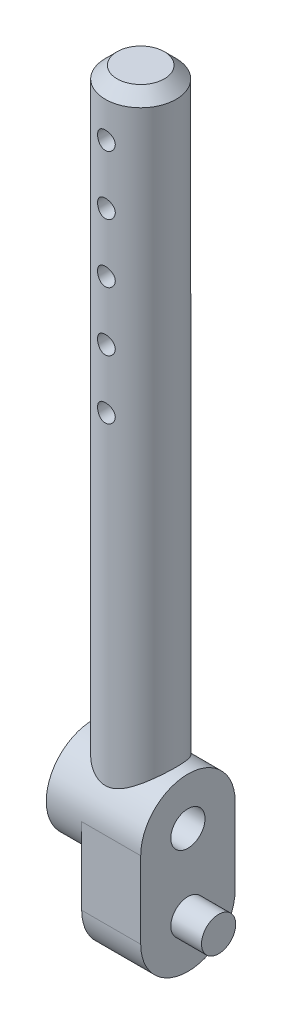
from build123d import *

# Parameters (mm, degrees)
SKETCH1_R               = 1.45
BOSS_EXTRUDE1_DEPTH     = 5
SKETCH2_R               = 1.45
BOSS_EXTRUDE2_DEPTH     = 2.6
SKETCH3_R               = 1.45
BOSS_EXTRUDE3_DEPTH     = 3
SKETCH5_W               = 3
SKETCH5_H               = 52.5
CHAMFER1_SIZE           = 1
SKETCH6_R               = 0.75
CUT_EXTRUDE1_DEPTH      = 5.0000001
CUT_EXTRUDE1_DEPTH_BACK = 5.0000001


with BuildPart() as part:
    # Sketch1 → Boss-Extrude1 (new body)
    with BuildSketch(Plane(origin=(0, 0, 0), x_dir=(0, 0, -1), z_dir=(1, 0, 0))):
        with BuildLine():
            Line((-4, 0), (-4, 6.5))
            ThreePointArc((-4, 6.5), (0, 10.5), (4, 6.5))
            Line((4, 6.5), (4, 0))
            ThreePointArc((4, 0), (0, -4), (-4, 0))
        make_face()
        with Locations((0, 6.5)):
            Circle(SKETCH1_R, mode=Mode.SUBTRACT)
    extrude(amount=BOSS_EXTRUDE1_DEPTH)

    # Sketch2 → Boss-Extrude2 (add)
    with BuildSketch(Plane(origin=(5, 0, 0), x_dir=(0, 0, -1), z_dir=(1, 0, 0))):
        with Locations((0, 0.05)):
            Circle(SKETCH2_R)
    extrude(amount=BOSS_EXTRUDE2_DEPTH)

    # Sketch3 → Boss-Extrude3 (add)
    with BuildSketch(Plane.ZY):
        with BuildLine():
            ThreePointArc((-4, 6.5), (0, 2.5), (4, 6.5))
            ThreePointArc((4, 6.5), (0, 10.5), (-4, 6.5))
        make_face()
        with Locations((0, 6.5)):
            Circle(SKETCH3_R, mode=Mode.SUBTRACT)
    extrude(amount=BOSS_EXTRUDE3_DEPTH)

    # Sketch5 → Revolve2 (revolve)
    with BuildSketch(Plane.XY):
        with Locations((2.5, 34.25)):
            Rectangle(SKETCH5_W, SKETCH5_H)
    revolve(axis=Axis((1, 60.5, 0), (0, -1, 0)))

    # Chamfer1
    chamfer1_edges = [part.edges().sort_by_distance(p)[0] for p in [
        (-2, 60.5, 0),
    ]]
    chamfer(chamfer1_edges, length=CHAMFER1_SIZE)

    # Sketch6 → Cut-Extrude1 (cut, two sides)
    with BuildSketch(Plane.XY) as cut_extrude1_sk:
        with Locations((1, 56.5)):
            Circle(SKETCH6_R)
        with Locations((1, 51.5)):
            Circle(SKETCH6_R)
        with Locations((1, 46.5)):
            Circle(SKETCH6_R)
        with Locations((1, 41.5)):
            Circle(SKETCH6_R)
        with Locations((1, 36.5)):
            Circle(SKETCH6_R)
    extrude(amount=CUT_EXTRUDE1_DEPTH, mode=Mode.SUBTRACT)
    extrude(cut_extrude1_sk.sketch, amount=-CUT_EXTRUDE1_DEPTH_BACK, mode=Mode.SUBTRACT)


solid = part.part
